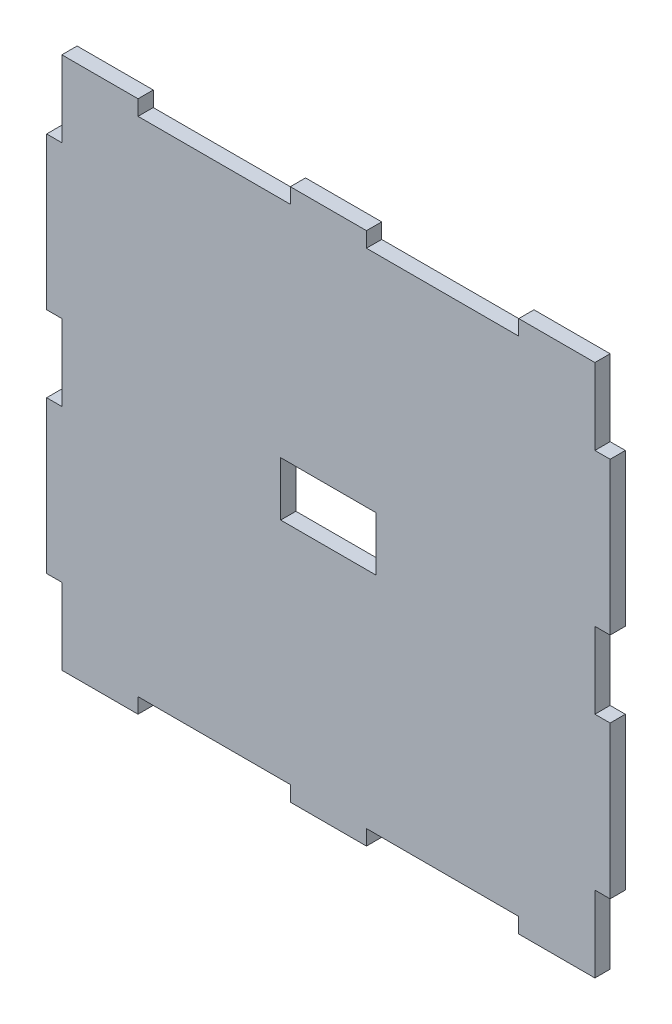
from build123d import *

# Parameters (mm, degrees)
SKETCH1_W           = 70
SKETCH1_H           = 70
BOSS_EXTRUDE1_DEPTH = 2
SKETCH2_W           = 2
SKETCH2_H           = 20
BOSS_EXTRUDE2_DEPTH = 2
SKETCH3_W           = 20
SKETCH3_H           = 2
CUT_EXTRUDE1_DEPTH  = 2
SKETCH4_W           = 12.53
SKETCH4_H           = 7.1
CUT_EXTRUDE2_DEPTH  = 10


with BuildPart() as part:
    # Sketch1 → Boss-Extrude1 (new body)
    with BuildSketch(Plane.XY):
        Rectangle(SKETCH1_W, SKETCH1_H)
    extrude(amount=-BOSS_EXTRUDE1_DEPTH)

    # Sketch2 → Boss-Extrude2 (add)
    with BuildSketch(Plane.XY):
        with Locations((-36, 15)):
            Rectangle(SKETCH2_W, SKETCH2_H)
        with Locations((-36, -15)):
            Rectangle(SKETCH2_W, SKETCH2_H)
        with Locations((36, -15)):
            Rectangle(SKETCH2_W, SKETCH2_H)
        with Locations((36, 15)):
            Rectangle(SKETCH2_W, SKETCH2_H)
    extrude(amount=-BOSS_EXTRUDE2_DEPTH)

    # Sketch3 → Cut-Extrude1 (cut)
    with BuildSketch(Plane.XY):
        with Locations((-15, 34)):
            Rectangle(SKETCH3_W, SKETCH3_H)
        with Locations((15, 34)):
            Rectangle(SKETCH3_W, SKETCH3_H)
        with Locations((-15, -34)):
            Rectangle(SKETCH3_W, SKETCH3_H)
        with Locations((15, -34)):
            Rectangle(SKETCH3_W, SKETCH3_H)
    extrude(amount=-CUT_EXTRUDE1_DEPTH, mode=Mode.SUBTRACT)

    # Sketch4 → Cut-Extrude2 (cut)
    with BuildSketch(Plane.XY):
        Rectangle(SKETCH4_W, SKETCH4_H)
    extrude(amount=-CUT_EXTRUDE2_DEPTH, mode=Mode.SUBTRACT)


solid = part.part
